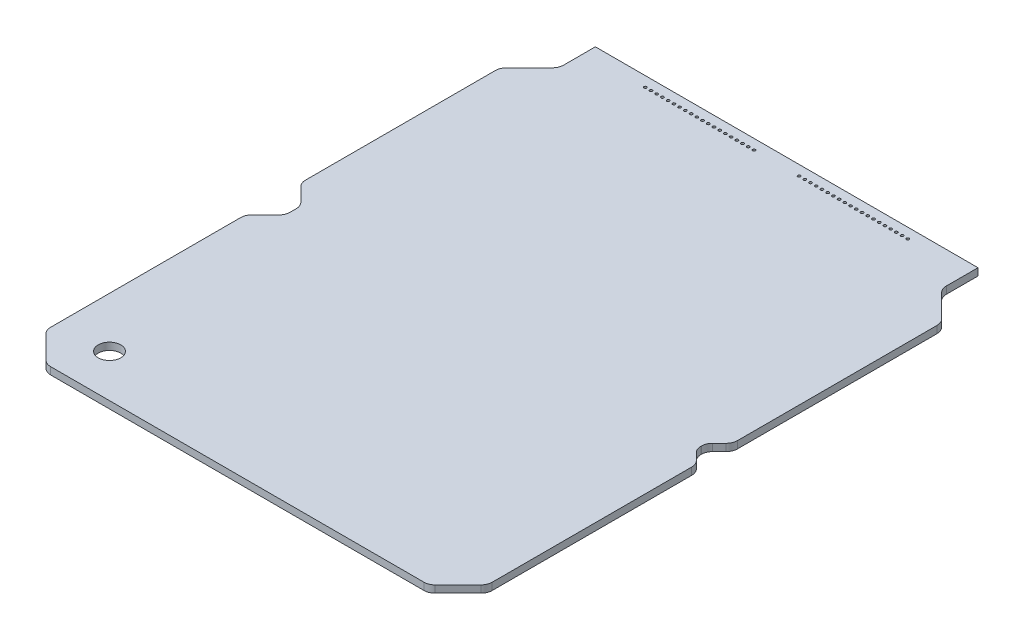
from build123d import *

# Parameters (mm, degrees)
BOSS_EXTRUDE1_DEPTH = 1.6
FILLET1_R           = 2.5
SKETCH15_R          = 2.5
CUT_EXTRUDE5_DEPTH  = 2.6
SKETCH16_R          = 0.3
CUT_EXTRUDE6_DEPTH  = 2.6


with BuildPart() as part:
    # Sketch1 → Boss-Extrude1 (new body)
    with BuildSketch(Plane(origin=(0, 0, 0), x_dir=(1, 0, 0), z_dir=(0, 1, 0))):
        Polygon((-49, 6.540916192), (-42.459083808, 0), (42.459083808, 0), (49, 6.540916192), (49, 50.753104052), (49, 52.874424396), (46.028679707, 55.845744689), (46.028679707, 57.999655213), (49, 60.970975506), (49, 63.09229585), (49, 107.30448371), (42.459083808, 113.845399902), (42.459083808, 121.922399609), (-42.459083808, 121.922399609), (-42.459083808, 113.845399902), (-49, 107.30448371), (-49, 63.09229585), (-44.528679707, 58.620975557), (-44.528679707, 55.224424345), (-49, 50.753104052), align=None)
    extrude(amount=BOSS_EXTRUDE1_DEPTH)

    # Fillet1
    fillet1_edges = [part.edges().sort_by_distance(p)[0] for p in [
        (49, 0.8, -6.540916192),
        (42.459083808, 0.8, 0),
        (-42.459083808, 0.8, 0),
        (-49, 0.8, -6.540916192),
        (-49, 0.8, -50.753104052),
        (-44.528679707, 0.8, -55.224424345),
        (-44.528679707, 0.8, -58.620975557),
        (-49, 0.8, -63.09229585),
        (-49, 0.8, -107.30448371),
        (-42.459083808, 0.8, -113.845399902),
        (42.459083808, 0.8, -113.845399902),
        (49, 0.8, -107.30448371),
        (49, 0.8, -60.970975506),
        (46.028679707, 0.8, -57.999655213),
        (46.028679707, 0.8, -55.845744689),
        (49, 0.8, -52.874424396),
    ]]
    fillet(fillet1_edges, radius=FILLET1_R)

    # Sketch15 → Cut-Extrude5 (cut, through all)
    with BuildSketch(Plane(origin=(0, 1.6, 0), x_dir=(1, 0, 0), z_dir=(0, 1, 0))):
        with Locations((-37.846, 9.4767)):
            Circle(SKETCH15_R)
    extrude(amount=-CUT_EXTRUDE5_DEPTH, mode=Mode.SUBTRACT)

    # Sketch16 → Cut-Extrude6 (cut, through all)
    with BuildSketch(Plane(origin=(0, 1.6, 0), x_dir=(1, 0, 0), z_dir=(0, 1, 0))):
        with Locations((-29.13, 119.672399609)):
            Circle(SKETCH16_R)
        with Locations((-27.86, 119.672399609)):
            Circle(SKETCH16_R)
        with Locations((-26.59, 119.672399609)):
            Circle(SKETCH16_R)
        with Locations((-25.32, 119.672399609)):
            Circle(SKETCH16_R)
        with Locations((-24.05, 119.672399609)):
            Circle(SKETCH16_R)
        with Locations((-22.78, 119.672399609)):
            Circle(SKETCH16_R)
        with Locations((-21.51, 119.672399609)):
            Circle(SKETCH16_R)
        with Locations((-20.24, 119.672399609)):
            Circle(SKETCH16_R)
        with Locations((-18.97, 119.672399609)):
            Circle(SKETCH16_R)
        with Locations((-17.7, 119.672399609)):
            Circle(SKETCH16_R)
        with Locations((-16.43, 119.672399609)):
            Circle(SKETCH16_R)
        with Locations((-15.16, 119.672399609)):
            Circle(SKETCH16_R)
        with Locations((-13.89, 119.672399609)):
            Circle(SKETCH16_R)
        with Locations((-12.62, 119.672399609)):
            Circle(SKETCH16_R)
        with Locations((-11.35, 119.672399609)):
            Circle(SKETCH16_R)
        with Locations((-10.08, 119.672399609)):
            Circle(SKETCH16_R)
        with Locations((-8.81, 119.672399609)):
            Circle(SKETCH16_R)
        with Locations((-7.54, 119.672399609)):
            Circle(SKETCH16_R)
        with Locations((-6.27, 119.672399609)):
            Circle(SKETCH16_R)
        with Locations((-5, 119.672399609)):
            Circle(SKETCH16_R)
        with Locations((5, 119.672399609)):
            Circle(SKETCH16_R)
        with Locations((6.27, 119.672399609)):
            Circle(SKETCH16_R)
        with Locations((7.54, 119.672399609)):
            Circle(SKETCH16_R)
        with Locations((8.81, 119.672399609)):
            Circle(SKETCH16_R)
        with Locations((10.08, 119.672399609)):
            Circle(SKETCH16_R)
        with Locations((11.35, 119.672399609)):
            Circle(SKETCH16_R)
        with Locations((12.62, 119.672399609)):
            Circle(SKETCH16_R)
        with Locations((13.89, 119.672399609)):
            Circle(SKETCH16_R)
        with Locations((15.16, 119.672399609)):
            Circle(SKETCH16_R)
        with Locations((16.43, 119.672399609)):
            Circle(SKETCH16_R)
        with Locations((17.7, 119.672399609)):
            Circle(SKETCH16_R)
        with Locations((18.97, 119.672399609)):
            Circle(SKETCH16_R)
        with Locations((20.24, 119.672399609)):
            Circle(SKETCH16_R)
        with Locations((21.51, 119.672399609)):
            Circle(SKETCH16_R)
        with Locations((22.78, 119.672399609)):
            Circle(SKETCH16_R)
        with Locations((24.05, 119.672399609)):
            Circle(SKETCH16_R)
        with Locations((25.32, 119.672399609)):
            Circle(SKETCH16_R)
        with Locations((26.59, 119.672399609)):
            Circle(SKETCH16_R)
        with Locations((27.86, 119.672399609)):
            Circle(SKETCH16_R)
        with Locations((29.13, 119.672399609)):
            Circle(SKETCH16_R)
    extrude(amount=-CUT_EXTRUDE6_DEPTH, mode=Mode.SUBTRACT)


solid = part.part
